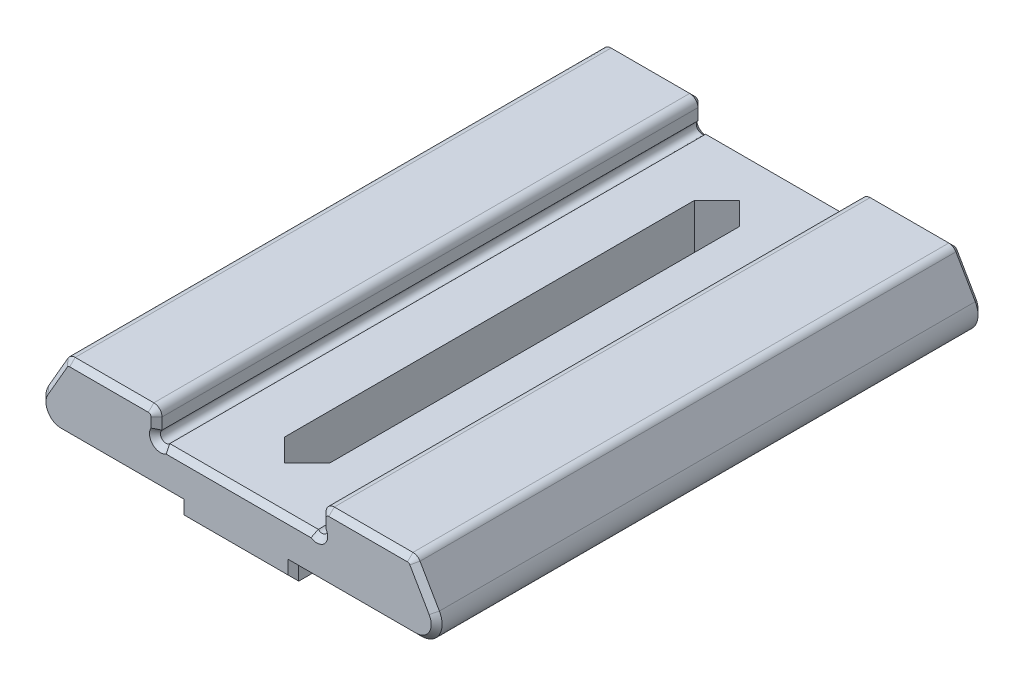
from build123d import *

# Parameters (mm, degrees)
BOSS_EXTRUDE1_DEPTH = 40
SKETCH2_W           = 8
SKETCH2_H           = 40
BOSS_EXTRUDE2_DEPTH = 1
CUT_EXTRUDE1_DEPTH  = 5
FILLET1_R           = 0.6
CHAMFER1_SIZE       = 0.4


with BuildPart() as part:
    # Sketch1 → Boss-Extrude1 (new body)
    with BuildSketch(Plane.XY):
        with BuildLine():
            Line((-12.988675135, 0), (0, 0))
            Line((0, 0), (12.988675135, 0))
            ThreePointArc((12.988675135, 0), (14.28771324, 0.75), (14.28771324, 2.25))
            Line((14.28771324, 2.25), (12.7, 5))
            Line((12.7, 5), (6, 5))
            Line((6, 5), (6, 3.565685425))
            ThreePointArc((6, 3.565685425), (6, 3), (5.434314575, 3))
            Line((5.434314575, 3), (-5.434314575, 3))
            ThreePointArc((-5.434314575, 3), (-6, 3), (-6, 3.565685425))
            Line((-6, 3.565685425), (-6, 5))
            Line((-6, 5), (-12.7, 5))
            Line((-12.7, 5), (-14.28771324, 2.25))
            ThreePointArc((-14.28771324, 2.25), (-14.28771324, 0.75), (-12.988675135, 0))
        make_face()
    extrude(amount=-BOSS_EXTRUDE1_DEPTH)

    # Sketch2 → Boss-Extrude2 (add)
    with BuildSketch(Plane.XZ):
        with Locations((0, -20)):
            Rectangle(SKETCH2_W, SKETCH2_H)
    extrude(amount=BOSS_EXTRUDE2_DEPTH)

    # Sketch3 → Cut-Extrude1 (cut, through all)
    with BuildSketch(Plane(origin=(0, 3, 0), x_dir=(1, 0, 0), z_dir=(0, 1, 0))):
        Polygon((0, 3.35), (1.65, 5), (1.65, 35), (0, 36.65), (-1.65, 35), (-1.65, 5), align=None)
    extrude(amount=-CUT_EXTRUDE1_DEPTH, mode=Mode.SUBTRACT)

    # Fillet1
    fillet1_edges = [part.edges().sort_by_distance(p)[0] for p in [
        (-12.7, 5, -20),
        (-6, 5, -20),
        (6, 5, -20),
        (12.7, 5, -20),
    ]]
    fillet(fillet1_edges, radius=FILLET1_R)

    # Chamfer1
    chamfer1_edges = [part.edges().sort_by_distance(p)[0] for p in [
        (-6, 3.982842712, 0),
        (-6, 3, 0),
        (0, 3, 0),
        (6, 3, 0),
        (13.580459161, 3.475, 0),
        (14.28771324, 0.75, 0),
        (14.28771324, 0.75, -40),
        (-8.494337567, 0, 0),
        (-14.28771324, 0.75, 0),
        (13.580459161, 3.475, -40),
        (6, 3, -40),
        (0, 3, -40),
        (8.494337567, 0, 0),
        (8.494337567, 0, -40),
        (4, -0.5, 0),
        (-6, 3, -40),
        (-4, -0.5, -40),
        (4, -0.5, -40),
        (0, -1, 0),
        (0, -1, -40),
        (-6, 3.982842712, -40),
        (-14.28771324, 0.75, -40),
        (9.476794919, 5, 0),
        (9.476794919, 5, -40),
        (6, 3.982842712, 0),
        (-9.476794919, 5, 0),
        (-13.580459161, 3.475, 0),
        (-6.175735931, 4.824264069, 0),
        (-12.653589838, 4.919615242, 0),
        (12.653589838, 4.919615242, 0),
        (6.175735931, 4.824264069, 0),
        (6, 3.982842712, -40),
        (-13.580459161, 3.475, -40),
        (-9.476794919, 5, -40),
        (-6.175735931, 4.824264069, -40),
        (-12.653589838, 4.919615242, -40),
        (12.653589838, 4.919615242, -40),
        (6.175735931, 4.824264069, -40),
        (-8.494337567, 0, -40),
    ]]
    chamfer(chamfer1_edges, length=CHAMFER1_SIZE)


solid = part.part
